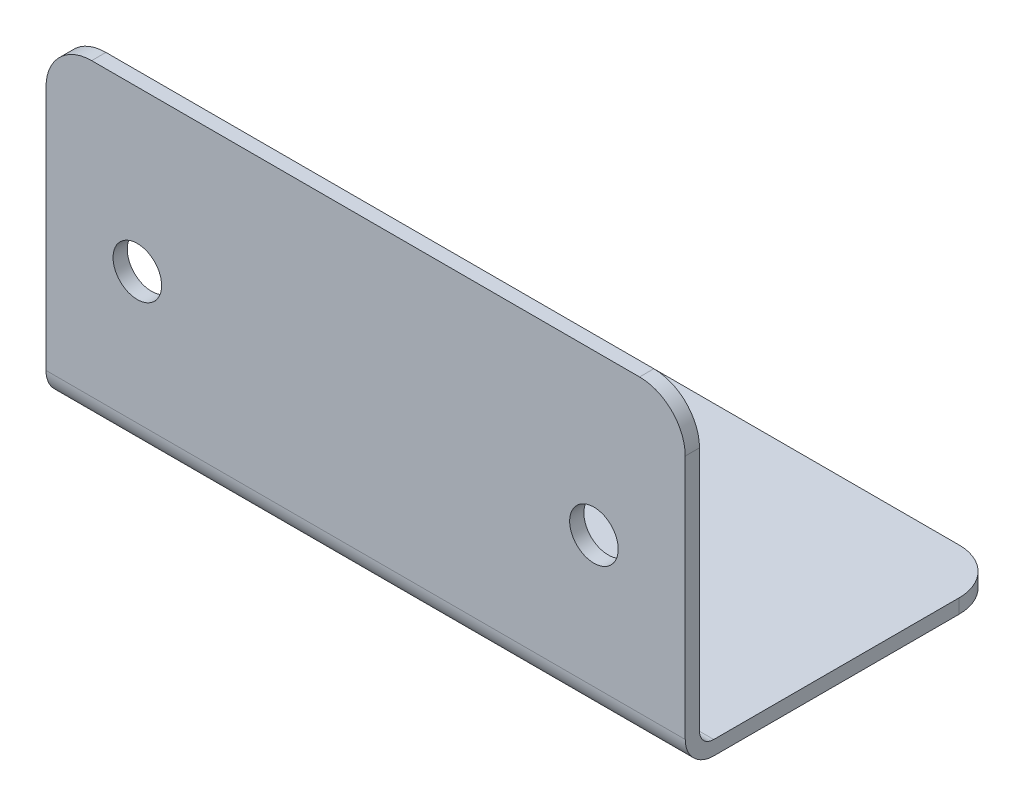
from build123d import *

# Parameters (mm, degrees)
BOSS_EXTRUDE1_DEPTH = 88.9
FILLET1_R           = 1.9812
FILLET2_R           = 3.9624
FILLET3_R           = 6.35
SKETCH2_R           = 3.3782
CUT_EXTRUDE1_DEPTH  = 88.9


with BuildPart() as part:
    # Sketch1 → Boss-Extrude1 (new body)
    with BuildSketch(Plane(origin=(0, 0, 0), x_dir=(0, 0, -1), z_dir=(1, 0, 0))):
        Polygon((0, 44.45), (0, 0), (44.45, 0), (44.45, 1.9812), (1.9812, 1.9812), (1.9812, 44.45), align=None)
    extrude(amount=BOSS_EXTRUDE1_DEPTH)

    # Fillet1
    fillet1_edges = [part.edges().sort_by_distance(p)[0] for p in [
        (44.45, 1.9812, -1.9812),
    ]]
    fillet(fillet1_edges, radius=FILLET1_R)

    # Fillet2
    fillet2_edges = [part.edges().sort_by_distance(p)[0] for p in [
        (44.45, 0, 0),
    ]]
    fillet(fillet2_edges, radius=FILLET2_R)

    # Fillet3
    fillet3_edges = [part.edges().sort_by_distance(p)[0] for p in [
        (88.9, 0.9906, -44.45),
        (88.9, 44.45, -0.9906),
        (0, 0.9906, -44.45),
        (0, 44.45, -0.9906),
    ]]
    fillet(fillet3_edges, radius=FILLET3_R)

    # Sketch2 → Cut-Extrude1 (cut)
    with BuildSketch(Plane.XY):
        with Locations((12.7, 22.225)):
            Circle(SKETCH2_R)
        with Locations((76.2, 22.225)):
            Circle(SKETCH2_R)
    extrude(amount=-CUT_EXTRUDE1_DEPTH, mode=Mode.SUBTRACT)


solid = part.part
